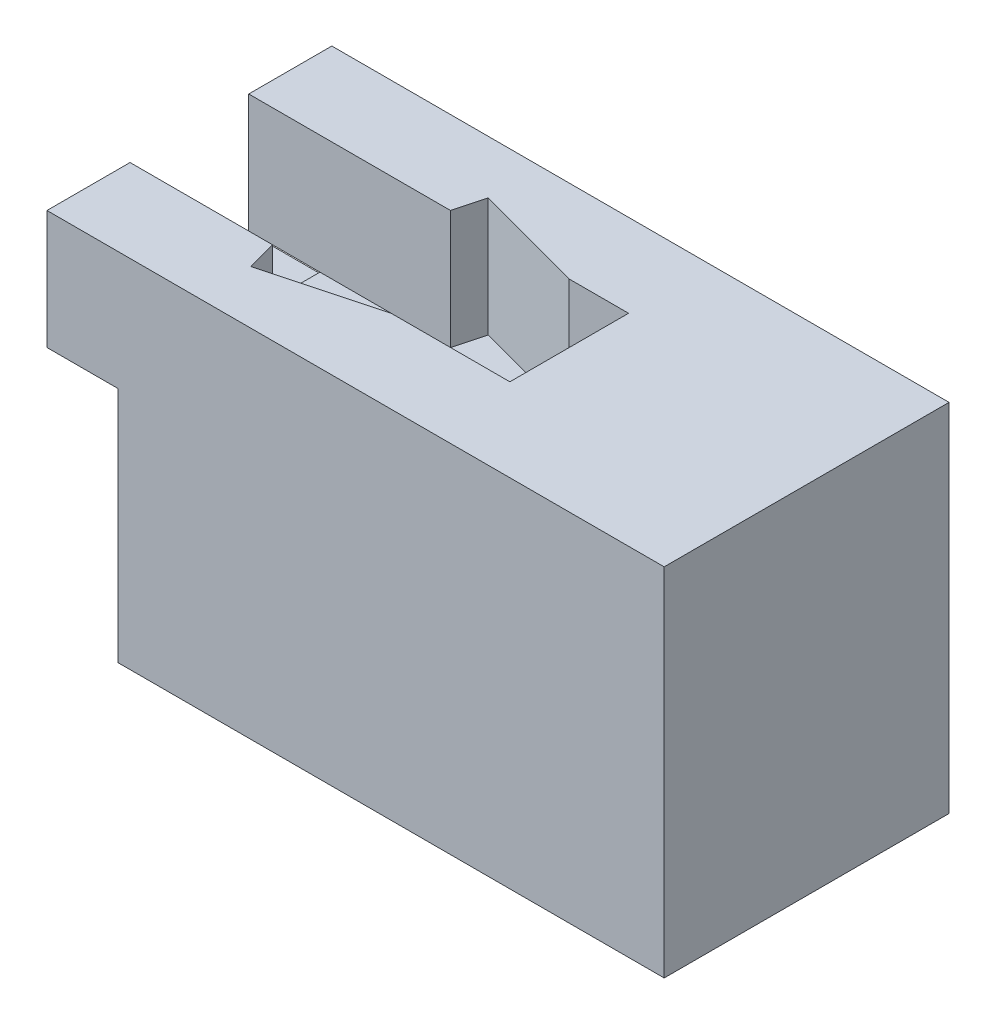
from build123d import *

# Parameters (mm, degrees)
SKETCH_1_W          = 120
SKETCH_1_H          = 150
EXTRUDE_1_DEPTH     = 200
CUT_EXTRUDE_1_DEPTH = 50
EXTRUDE_3_DEPTH     = 30
SKETCH_4_W          = 35
SKETCH_4_H          = 50
EXTRUDE_4_DEPTH     = 30
SKETCH_5_W          = 50
SKETCH_5_H          = 99.5
EXTRUDE_7_DEPTH     = 30


with BuildPart() as part:
    # 草图1 → 凸台-拉伸1 (new body)
    with BuildSketch(Plane(origin=(0, 0, 0), x_dir=(0, 0, -1), z_dir=(1, 0, 0))):
        with Locations((60, 75)):
            Rectangle(SKETCH_1_W, SKETCH_1_H)
    extrude(amount=EXTRUDE_1_DEPTH)

    # 草图2 → 切除-拉伸1 (cut)
    with BuildSketch(Plane(origin=(0, 150, 0), x_dir=(1, 0, 0), z_dir=(0, 1, 0))):
        Polygon((75, 85), (25, 85), (71.650635095, 72.5), align=None)
        Polygon((28.349364905, 97.5), (25, 85), (75, 85), align=None)
        Polygon((25, 85), (0, 85), (0, 35), (46.650635095, 47.5), (50, 35), (100, 35), (100, 85), (75, 85), (71.650635095, 72.5), align=None)
        Polygon((46.650635095, 47.5), (0, 35), (50, 35), align=None)
        Polygon((50, 35), (0, 35), (3.349364905, 22.5), align=None)
    extrude(amount=-CUT_EXTRUDE_1_DEPTH, mode=Mode.SUBTRACT)

    # 草图3 → 凸台-拉伸3 (add)
    with BuildSketch(Plane.ZY):
        Polygon((-35, 100), (-85, 100), (-85, 150), (-120, 150), (-120, 0), (0, 0), (0, 150), (-35, 150), align=None)
    extrude(amount=EXTRUDE_3_DEPTH)

    # 草图4 → 凸台-拉伸4 (add)
    with BuildSketch(Plane.ZY.offset(30)):
        with Locations((-102.5, 125)):
            Rectangle(SKETCH_4_W, SKETCH_4_H)
        with Locations((-17.5, 125)):
            Rectangle(SKETCH_4_W, SKETCH_4_H)
    extrude(amount=EXTRUDE_4_DEPTH)

    # 草图5 → 凸台-拉伸7 (add)
    with BuildSketch(Plane.ZY.offset(30)):
        with Locations((-60, 49.75)):
            Rectangle(SKETCH_5_W, SKETCH_5_H)
    extrude(amount=EXTRUDE_7_DEPTH)


solid = part.part
